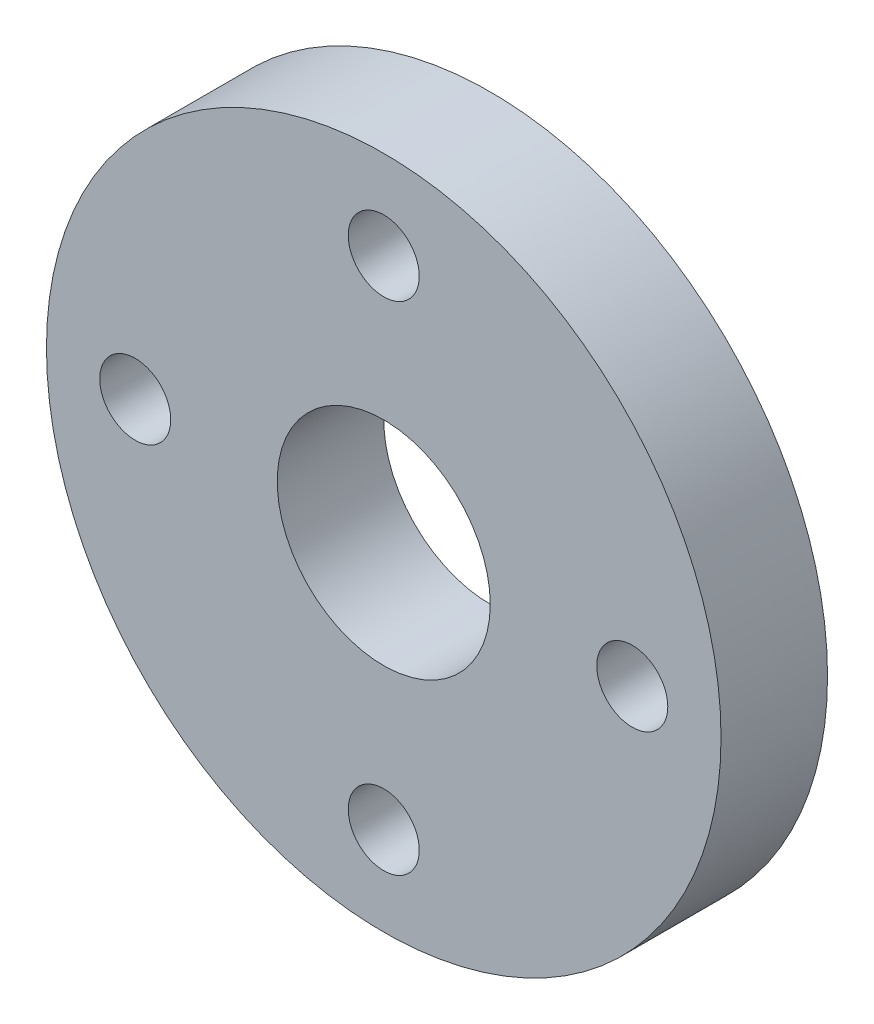
from build123d import *

# Parameters (mm, degrees)
SKETCH1_R           = 9.5
SKETCH1_R_2         = 1
SKETCH1_R_3         = 3
BOSS_EXTRUDE1_DEPTH = 3


with BuildPart() as part:
    # Sketch1 → Boss-Extrude1 (new body)
    with BuildSketch(Plane.XY):
        Circle(SKETCH1_R)
        with Locations((0, 7)):
            Circle(SKETCH1_R_2, mode=Mode.SUBTRACT)
        with Locations((7, 0)):
            Circle(SKETCH1_R_2, mode=Mode.SUBTRACT)
        with Locations((0, -7)):
            Circle(SKETCH1_R_2, mode=Mode.SUBTRACT)
        with Locations((-7, 0)):
            Circle(SKETCH1_R_2, mode=Mode.SUBTRACT)
        Circle(SKETCH1_R_3, mode=Mode.SUBTRACT)
    extrude(amount=BOSS_EXTRUDE1_DEPTH)


solid = part.part
